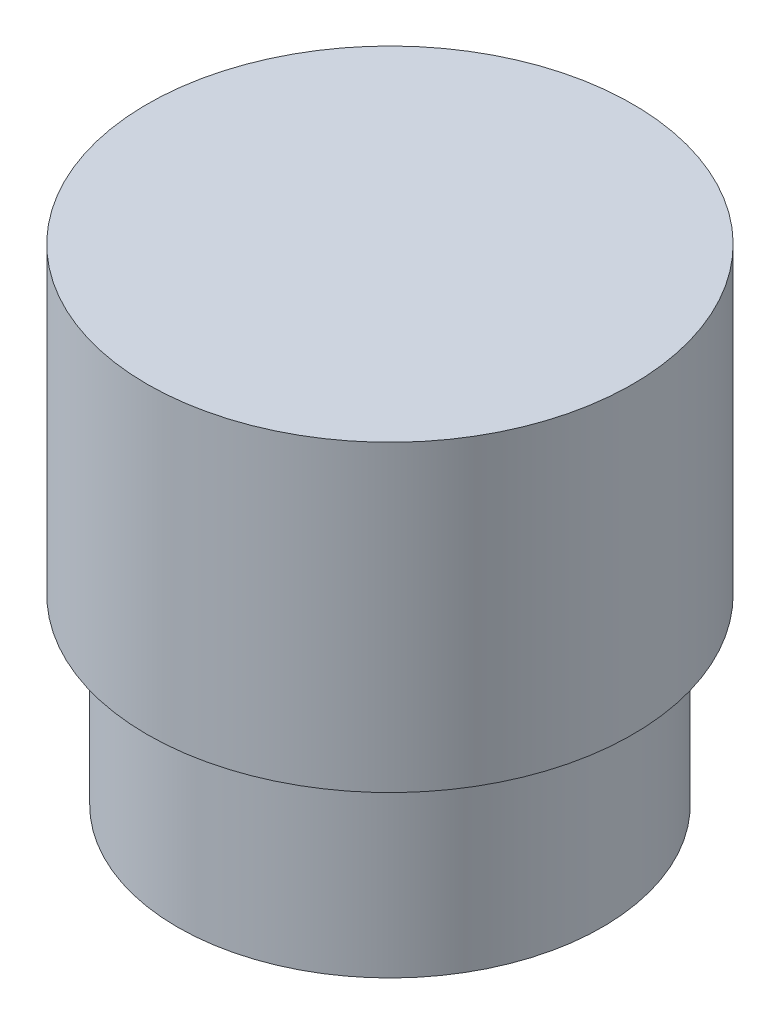
from build123d import *

# Parameters (mm, degrees)
SKETCH2_R          = 2.775
CUT_EXTRUDE1_DEPTH = 3


with BuildPart() as part:
    # Sketch1 → Revolve1 (revolve)
    with BuildSketch(Plane.XY):
        Polygon((0, 0), (3.5, 0), (3.5, 3), (4, 3), (4, 8), (0, 8), align=None)
    revolve(axis=Axis((0, 8, 0), (0, -1, 0)))

    # Sketch2 → Cut-Extrude1 (cut)
    with BuildSketch(Plane.XZ):
        Circle(SKETCH2_R)
    extrude(amount=-CUT_EXTRUDE1_DEPTH, mode=Mode.SUBTRACT)


solid = part.part
